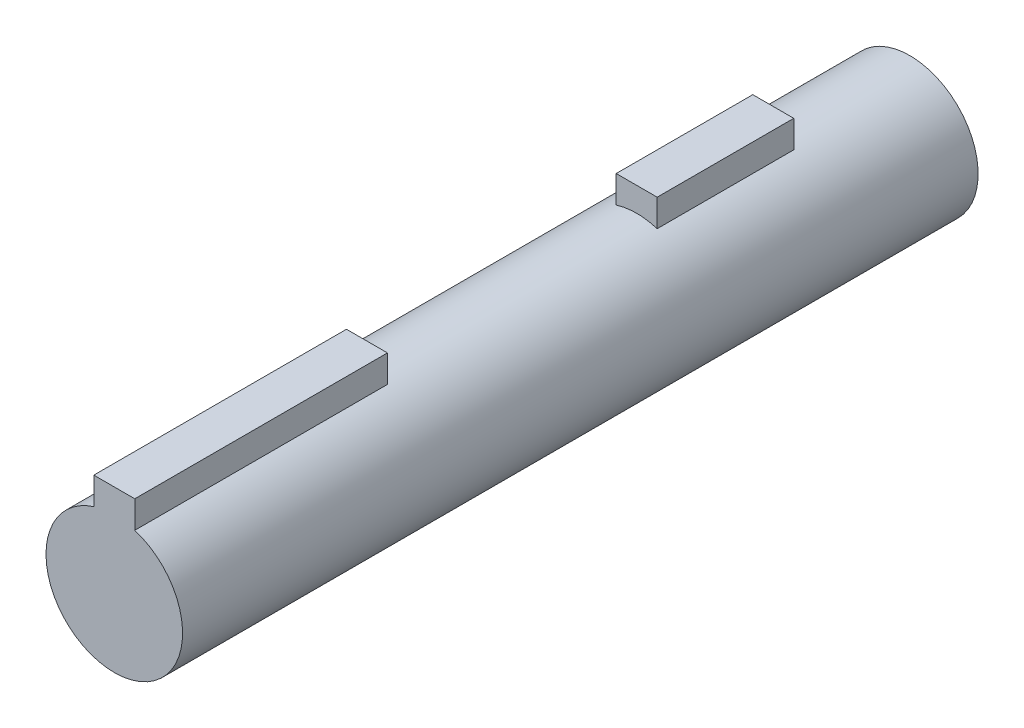
from build123d import *

# Parameters (mm, degrees)
SKETCH1_R            = 5
BOSS_EXTRUDE1_DEPTH  = 20
BOSS_EXTRUDE2_DEPTH  = 10
SKETCH4_R            = 5
BOSS_EXTRUDE3_DEPTH  = 27
BOSS_EXTRUDE4_DEPTH  = 19
SKETCH6_R            = 5
BOSS_EXTRUDE5_DEPTH  = 30
SKETCH7_R            = 5
CUT_EXTRUDE1_DEPTH   = 10
SKETCH8_R            = 6.933887
CUT_EXTRUDE2_DEPTH   = 35
SKETCH9_R            = 5
CUT_EXTRUDE3_DEPTH   = 12
SKETCH10_R           = 5
BOSS_EXTRUDE8_DEPTH  = 15
BOSS_EXTRUDE9_DEPTH  = 10
SKETCH12_R           = 5
BOSS_EXTRUDE10_DEPTH = 10
SKETCH13_R           = 5
CUT_EXTRUDE4_DEPTH   = 28
SKETCH20_R           = 5
CUT_EXTRUDE5_DEPTH   = 2
BOSS_EXTRUDE11_DEPTH = 4.25
CUT_EXTRUDE6_DEPTH   = 22.25
BOSS_EXTRUDE12_DEPTH = 17.5


with BuildPart() as part:
    # Sketch1 → Boss-Extrude1 (new body)
    with BuildSketch(Plane.XY):
        Circle(SKETCH1_R)
    extrude(amount=BOSS_EXTRUDE1_DEPTH)

    # Sketch3 → Boss-Extrude2 (add)
    with BuildSketch(Plane.XY.offset(20)):
        with BuildLine():
            Line((1.5, 6.769696), (-1.5, 6.769696))
            Line((-1.5, 6.769696), (-1.5, 4.769696))
            ThreePointArc((-1.5, 4.769696), (0, -5), (1.5, 4.769696))
            Line((1.5, 4.769696), (1.5, 6.769696))
        make_face()
    extrude(amount=BOSS_EXTRUDE2_DEPTH)

    # Sketch4 → Boss-Extrude3 (add)
    with BuildSketch(Plane.XY.offset(30)):
        Circle(SKETCH4_R)
    extrude(amount=BOSS_EXTRUDE3_DEPTH)

    # Sketch5 → Boss-Extrude4 (add)
    with BuildSketch(Plane.XY.offset(57)):
        with BuildLine():
            Line((-1.5, 4.769696), (-1.5, 6.769696))
            Line((-1.5, 6.769696), (1.5, 6.769696))
            Line((1.5, 6.769696), (1.5, 4.769696))
            ThreePointArc((1.5, 4.769696), (0, -5), (-1.5, 4.769696))
        make_face()
    extrude(amount=BOSS_EXTRUDE4_DEPTH)

    # Sketch6 → Boss-Extrude5 (add)
    with BuildSketch(Plane.XY.offset(76)):
        Circle(SKETCH6_R)
    extrude(amount=BOSS_EXTRUDE5_DEPTH)

    # Sketch7 → Cut-Extrude1 (cut)
    with BuildSketch(Plane(origin=(0, 0, 0), x_dir=(-1, 0, 0), z_dir=(0, 0, -1))):
        Circle(SKETCH7_R)
    extrude(amount=-CUT_EXTRUDE1_DEPTH, mode=Mode.SUBTRACT)

    # Sketch8 → Cut-Extrude2 (cut)
    with BuildSketch(Plane(origin=(0, 0, 10), x_dir=(-1, 0, 0), z_dir=(0, 0, -1))):
        Circle(SKETCH8_R)
    extrude(amount=-CUT_EXTRUDE2_DEPTH, mode=Mode.SUBTRACT)

    # Sketch9 → Cut-Extrude3 (cut)
    with BuildSketch(Plane(origin=(0, 0, 45), x_dir=(-1, 0, 0), z_dir=(0, 0, -1))):
        with Locations(Location((0, 0, 0), (0, 0, 72.542397))):
            Circle(SKETCH9_R)
    extrude(amount=-CUT_EXTRUDE3_DEPTH, mode=Mode.SUBTRACT)

    # Sketch10 → Boss-Extrude8 (add)
    with BuildSketch(Plane(origin=(0, 0, 57), x_dir=(-1, 0, 0), z_dir=(0, 0, -1))):
        Circle(SKETCH10_R)
    extrude(amount=BOSS_EXTRUDE8_DEPTH)

    # Sketch11 → Boss-Extrude9 (add)
    with BuildSketch(Plane(origin=(0, 0, 42), x_dir=(-1, 0, 0), z_dir=(0, 0, -1))):
        with BuildLine():
            Line((-1.5, 6.769696), (1.5, 6.769696))
            Line((1.5, 6.769696), (1.5, 4.769696))
            ThreePointArc((1.5, 4.769696), (0, -5), (-1.5, 4.769696))
            Line((-1.5, 4.769696), (-1.5, 6.769696))
        make_face()
    extrude(amount=BOSS_EXTRUDE9_DEPTH)

    # Sketch12 → Boss-Extrude10 (add)
    with BuildSketch(Plane(origin=(0, 0, 32), x_dir=(-1, 0, 0), z_dir=(0, 0, -1))):
        Circle(SKETCH12_R)
    extrude(amount=BOSS_EXTRUDE10_DEPTH)

    # Sketch13 → Cut-Extrude4 (cut)
    with BuildSketch(Plane.XY.offset(106)):
        with Locations(Location((0, 0, 0), (0, 0, 180))):
            Circle(SKETCH13_R)
    extrude(amount=-CUT_EXTRUDE4_DEPTH, mode=Mode.SUBTRACT)

    # Sketch20 → Cut-Extrude5 (cut)
    with BuildSketch(Plane.XY.offset(78)):
        with Locations(Location((0, 0, 0), (0, 0, 180))):
            Circle(SKETCH20_R)
    extrude(amount=-CUT_EXTRUDE5_DEPTH, mode=Mode.SUBTRACT)

    # Sketch21 → Boss-Extrude11 (add)
    with BuildSketch(Plane.XY.offset(76)):
        with BuildLine():
            Line((1.5, 4.769696), (1.5, 6.769696))
            Line((1.5, 6.769696), (-1.5, 6.769696))
            Line((-1.5, 6.769696), (-1.5, 4.769696))
            ThreePointArc((-1.5, 4.769696), (0, -5), (1.5, 4.769696))
        make_face()
    extrude(amount=BOSS_EXTRUDE11_DEPTH)

    # Sketch22 → Cut-Extrude6 (cut)
    with BuildSketch(Plane(origin=(0, 0, 57), x_dir=(-1, 0, 0), z_dir=(0, 0, -1))):
        with BuildLine():
            Line((1.5, 4.769696), (1.5, 6.769696))
            Line((1.5, 6.769696), (-1.5, 6.769696))
            Line((-1.5, 6.769696), (-1.5, 4.769696))
            ThreePointArc((-1.5, 4.769696), (0, 5), (1.5, 4.769696))
        make_face()
    extrude(amount=-CUT_EXTRUDE6_DEPTH, mode=Mode.SUBTRACT)

    # Sketch23 → Boss-Extrude12 (add)
    with BuildSketch(Plane(origin=(0, 0, 79.25), x_dir=(-1, 0, 0), z_dir=(0, 0, -1))):
        with BuildLine():
            Line((1.5, 4.769696), (1.5, 6.769696))
            Line((1.5, 6.769696), (-1.5, 6.769696))
            Line((-1.5, 6.769696), (-1.5, 4.769696))
            ThreePointArc((-1.5, 4.769696), (0, 5), (1.5, 4.769696))
        make_face()
    extrude(amount=BOSS_EXTRUDE12_DEPTH)


solid = part.part
